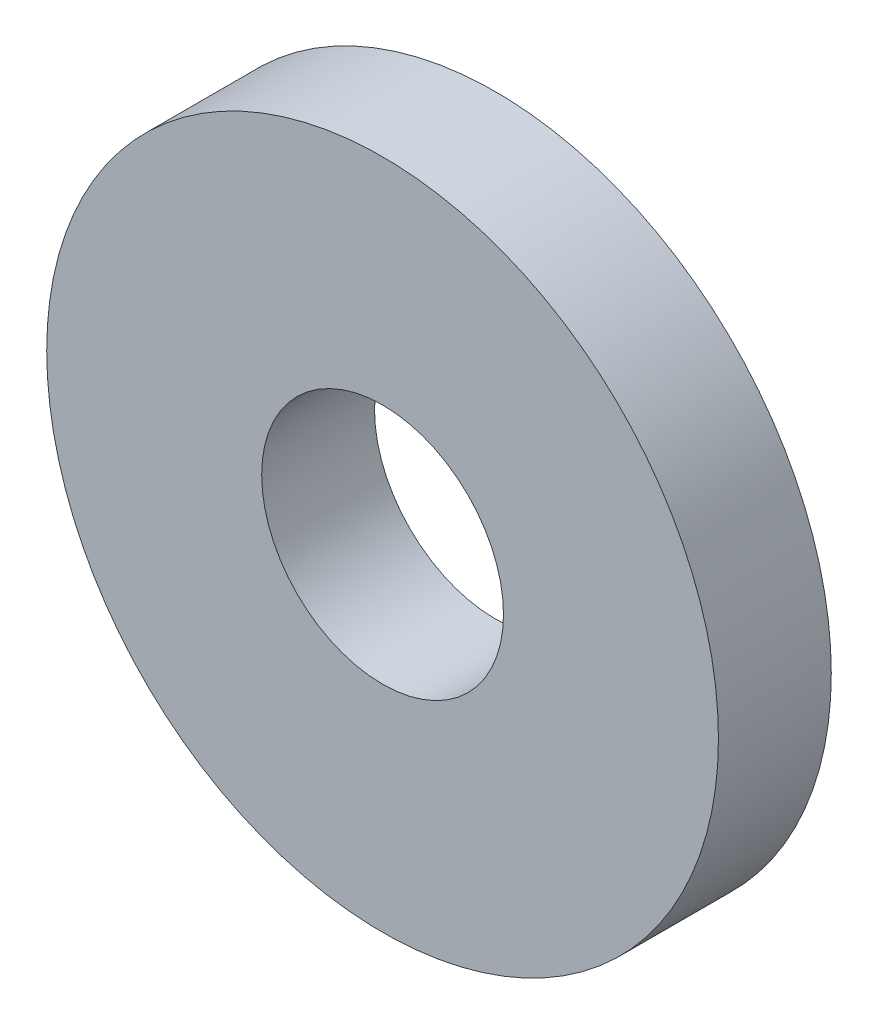
from build123d import *

# Parameters (mm, degrees)
SKETCH1_R           = 9.525
SKETCH1_R_2         = 3.429
BOSS_EXTRUDE1_DEPTH = 3.2004


with BuildPart() as part:
    # Sketch1 → Boss-Extrude1 (new body)
    with BuildSketch(Plane.XY):
        Circle(SKETCH1_R)
        Circle(SKETCH1_R_2, mode=Mode.SUBTRACT)
    extrude(amount=BOSS_EXTRUDE1_DEPTH)


solid = part.part
